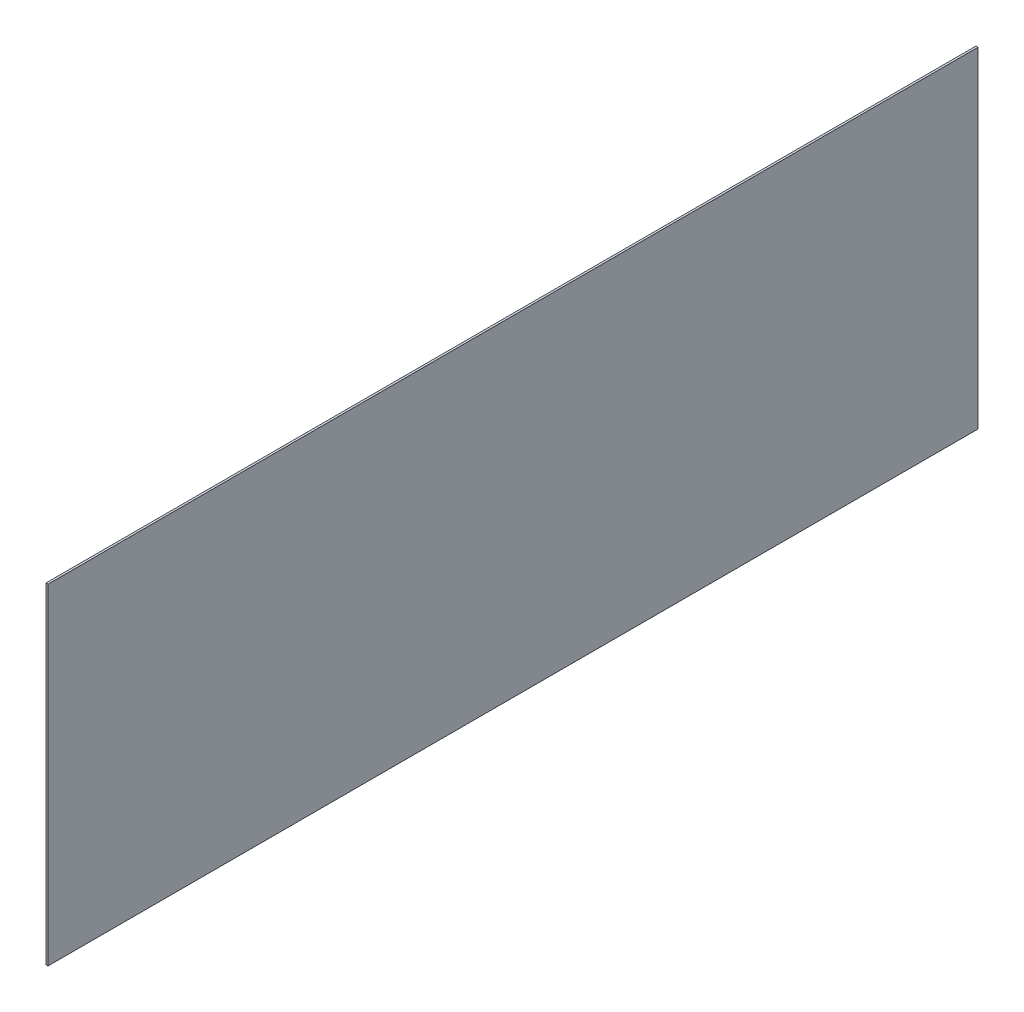
from build123d import *

# Parameters (mm, degrees)
SKETCH1_W           = 450
SKETCH1_H           = 160
BOSS_EXTRUDE1_DEPTH = 1


with BuildPart() as part:
    # Sketch1 → Boss-Extrude1 (new body)
    with BuildSketch(Plane(origin=(0, 0, 0), x_dir=(0, 0, -1), z_dir=(1, 0, 0))):
        Rectangle(SKETCH1_W, SKETCH1_H)
    extrude(amount=BOSS_EXTRUDE1_DEPTH)


solid = part.part
